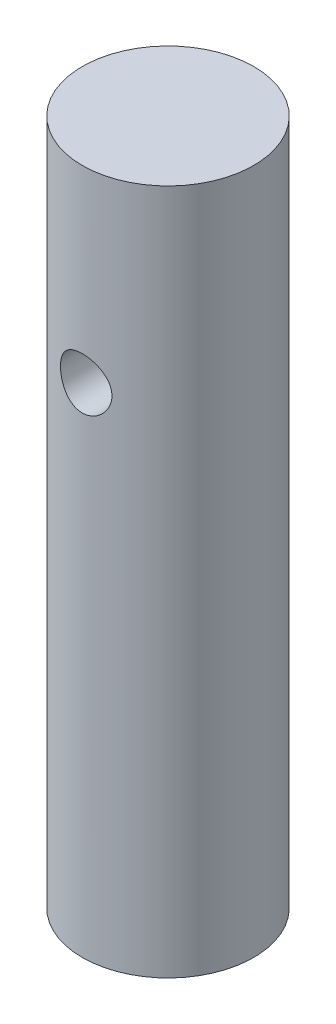
from build123d import *

# Parameters (mm, degrees)
CROQUIS1_R                        = 2.5
SALIENTE_EXTRUIR1_DEPTH           = 20
CORTAR_EXTRUIR1_REACH             = 4.5
CROQUIS2_R                        = 0.75
CORTAR_EXTRUIR1_DIRECTION_2_REACH = 4.5


with BuildPart() as part:
    # Croquis1 → Saliente-Extruir1 (new body)
    with BuildSketch(Plane(origin=(0, 0, 0), x_dir=(1, 0, 0), z_dir=(0, 1, 0))):
        Circle(CROQUIS1_R)
    extrude(amount=SALIENTE_EXTRUIR1_DEPTH)

    # Croquis2 → Cortar-Extruir1 (cut, up to next)
    with BuildSketch(Plane.XY, mode=Mode.PRIVATE) as cortar_extruir1_sk1:
        with Locations((0, 14.5)):
            Circle(CROQUIS2_R)
    cortar_extruir1_tool1 = extrude(cortar_extruir1_sk1.sketch, amount=-CORTAR_EXTRUIR1_REACH, mode=Mode.PRIVATE) & part.part
    add(cortar_extruir1_tool1.solids().sort_by_distance((0, 14.5, 0))[0], mode=Mode.SUBTRACT)

    # Croquis2 → Cortar-Extruir1 direction 2 (cut, up to next)
    with BuildSketch(Plane.XY, mode=Mode.PRIVATE) as cortar_extruir1_direction_2_sk1:
        with Locations((0, 14.5)):
            Circle(CROQUIS2_R)
    cortar_extruir1_direction_2_tool1 = extrude(cortar_extruir1_direction_2_sk1.sketch, amount=CORTAR_EXTRUIR1_DIRECTION_2_REACH, mode=Mode.PRIVATE) & part.part
    add(cortar_extruir1_direction_2_tool1.solids().sort_by_distance((0, 14.5, 0))[0], mode=Mode.SUBTRACT)


solid = part.part
